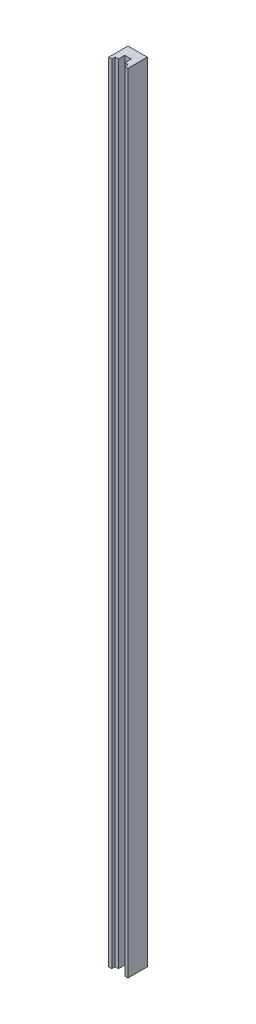
from build123d import *

# Parameters (mm, degrees)
SKETCH1_W                 = 30
SKETCH1_H                 = 30
BOSS_EXTRUDE1_DEPTH       = 1225
CUT_EXTRUDE1_REACH        = 1227
SKETCH2_W                 = 20
SKETCH2_H                 = 5
CUT_EXTRUDE2_REACH        = 1227
SKETCH3_W                 = 10
SKETCH3_H                 = 10
SKETCH6_R                 = 4
CUT_EXTRUDE3_DEPTH        = 3
M6X1_0_TAPPED_HOLE1_D     = 5
M6X1_0_TAPPED_HOLE1_DEPTH = 15
M6X1_0_TAPPED_HOLE1_TIP   = 1.502151548


with BuildPart() as part:
    # Sketch1 → Boss-Extrude1 (new body)
    with BuildSketch(Plane(origin=(0, 0, 0), x_dir=(1, 0, 0), z_dir=(0, 1, 0))):
        Rectangle(SKETCH1_W, SKETCH1_H)
    extrude(amount=BOSS_EXTRUDE1_DEPTH)

    # Sketch2 → Cut-Extrude1 (cut, up to next)
    with BuildSketch(Plane(origin=(0, 1225, 0), x_dir=(1, 0, 0), z_dir=(0, 1, 0)), mode=Mode.PRIVATE) as cut_extrude1_sk1:
        with Locations((0, -12.5)):
            Rectangle(SKETCH2_W, SKETCH2_H)
    cut_extrude1_tool1 = extrude(cut_extrude1_sk1.sketch, amount=-CUT_EXTRUDE1_REACH, mode=Mode.PRIVATE) & part.part
    add(cut_extrude1_tool1.solids().sort_by_distance((0, 1225, 12.5))[0], mode=Mode.SUBTRACT)

    # Sketch3 → Cut-Extrude2 (cut, up to next)
    with BuildSketch(Plane(origin=(0, 1225, 0), x_dir=(1, 0, 0), z_dir=(0, 1, 0)), mode=Mode.PRIVATE) as cut_extrude2_sk1:
        with Locations((0, -5)):
            Rectangle(SKETCH3_W, SKETCH3_H)
    cut_extrude2_tool1 = extrude(cut_extrude2_sk1.sketch, amount=-CUT_EXTRUDE2_REACH, mode=Mode.PRIVATE) & part.part
    add(cut_extrude2_tool1.solids().sort_by_distance((0, 1225, 5))[0], mode=Mode.SUBTRACT)

    # Sketch6 → Cut-Extrude3 (cut)
    with BuildSketch(Plane(origin=(0, 0, -15), x_dir=(-1, 0, 0), z_dir=(0, 0, -1))):
        with Locations((0, 1200)):
            Circle(SKETCH6_R)
        with Locations((0, 1000)):
            Circle(SKETCH6_R)
        with Locations((0, 800)):
            Circle(SKETCH6_R)
        with Locations((0, 700)):
            Circle(SKETCH6_R)
        with Locations((0, 650)):
            Circle(SKETCH6_R)
        with Locations((0, 600)):
            Circle(SKETCH6_R)
        with Locations((0, 550)):
            Circle(SKETCH6_R)
        with Locations((0, 500)):
            Circle(SKETCH6_R)
        with Locations((0, 450)):
            Circle(SKETCH6_R)
        with Locations((0, 400)):
            Circle(SKETCH6_R)
        with Locations((0, 350)):
            Circle(SKETCH6_R)
        with Locations((0, 300)):
            Circle(SKETCH6_R)
        with Locations((0, 250)):
            Circle(SKETCH6_R)
        with Locations((0, 200)):
            Circle(SKETCH6_R)
    extrude(amount=-CUT_EXTRUDE3_DEPTH, mode=Mode.SUBTRACT)

    # M6x1.0 Tapped Hole1
    with Locations(Plane(origin=(0, 0, -15), x_dir=(-1, 0, 0), z_dir=(0, 0, -1))):
        with Locations((0, 75), (0, 25)):
            Hole(M6X1_0_TAPPED_HOLE1_D / 2, depth=M6X1_0_TAPPED_HOLE1_DEPTH)
            with Locations((0, 0, -(M6X1_0_TAPPED_HOLE1_DEPTH + M6X1_0_TAPPED_HOLE1_TIP / 2))):  # 118° drill point
                Cone(0, M6X1_0_TAPPED_HOLE1_D / 2, M6X1_0_TAPPED_HOLE1_TIP, mode=Mode.SUBTRACT)


solid = part.part
